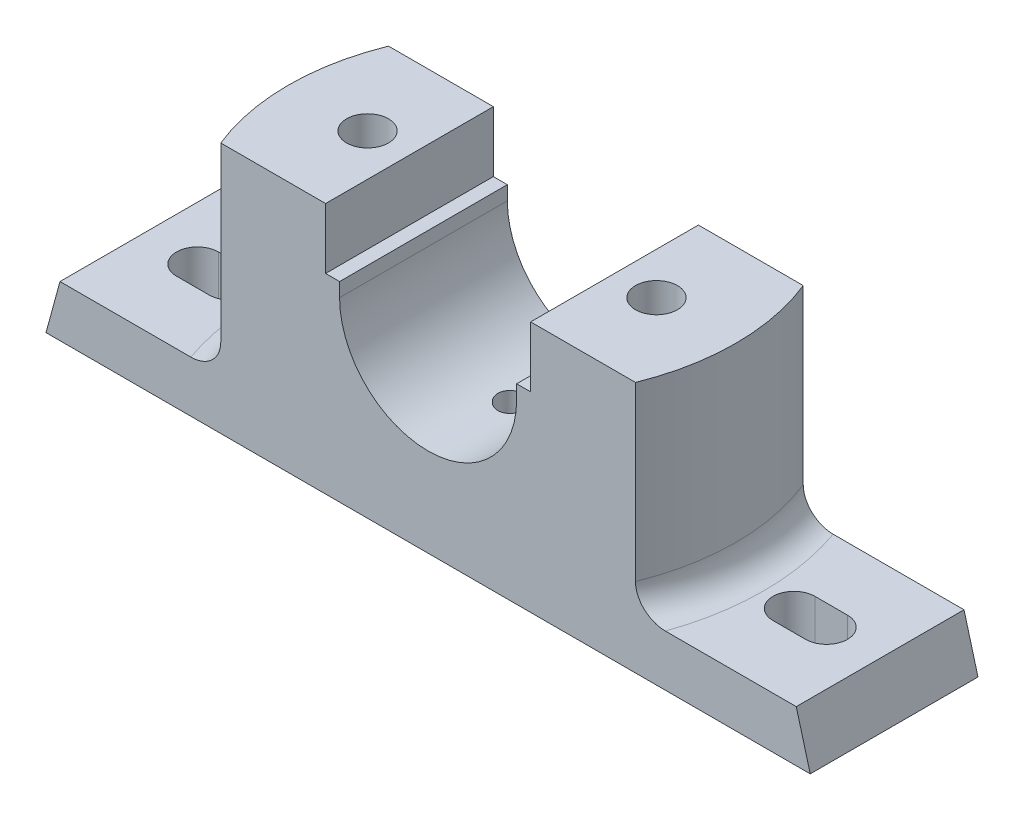
from build123d import *

# Parameters (mm, degrees)
BOSS_EXTRUDE1_DEPTH = 18
CUT_EXTRUDE1_DEPTH  = 43
SKETCH12_W          = 20
SKETCH12_H          = 20
CUT_EXTRUDE2_DEPTH  = 8
SKETCH13_R          = 4.5
CUT_EXTRUDE3_DEPTH  = 55
CUT_EXTRUDE4_DEPTH  = 12
CUT_EXTRUDE8_START  = -6
SKETCH18_R          = 3
CUT_EXTRUDE8_DEPTH  = 6.238337
FILLET1_R           = 6


with BuildPart() as part:
    # Sketch1 → Boss-Extrude1 (new body, symmetric)
    with BuildSketch(Plane.XY):
        with BuildLine():
            Line((82, 0), (-82, 0))
            Line((-82, 0), (-79, 11))
            Line((-79, 11), (-49, 11))
            Line((-49, 11), (-49, 54))
            Line((-49, 54), (-22, 54))
            Line((-22, 54), (-22, 41))
            Line((-22, 41), (-19, 41))
            Line((-19, 41), (-19, 38))
            ThreePointArc((-19, 38), (0, 19), (19, 38))
            Line((19, 38), (19, 41))
            Line((19, 41), (22, 41))
            Line((22, 41), (22, 54))
            Line((22, 54), (49, 54))
            Line((49, 54), (49, 11))
            Line((49, 11), (79, 11))
            Line((79, 11), (82, 0))
        make_face()
    extrude(amount=BOSS_EXTRUDE1_DEPTH, both=True)

    # Sketch3 → Cut-Extrude1 (cut)
    with BuildSketch(Plane(origin=(0, 54, 0), x_dir=(1, 0, 0), z_dir=(0, 1, 0))):
        with BuildLine():
            Line((-44.497190923, 18), (-49, 18))
            Line((-49, 18), (-49, -18))
            Line((-49, -18), (-44.497190923, -18))
            ThreePointArc((-44.497190923, -18), (-48, 0), (-44.497190923, 18))
        make_face()
        with BuildLine():
            Line((49, -18), (49, 18))
            Line((49, 18), (44.497190923, 18))
            ThreePointArc((44.497190923, 18), (48, 0), (44.497190923, -18))
            Line((44.497190923, -18), (49, -18))
        make_face()
    extrude(amount=-CUT_EXTRUDE1_DEPTH, mode=Mode.SUBTRACT)

    # Sketch12 → Cut-Extrude2 (cut)
    with BuildSketch(Plane.XZ):
        with Locations((-31, 0)):
            Rectangle(SKETCH12_W, SKETCH12_H)
        with Locations((31, 0)):
            Rectangle(SKETCH12_W, SKETCH12_H)
    extrude(amount=-CUT_EXTRUDE2_DEPTH, mode=Mode.SUBTRACT)

    # Sketch13 → Cut-Extrude3 (cut, through all)
    with BuildSketch(Plane(origin=(0, 54, 0), x_dir=(1, 0, 0), z_dir=(0, 1, 0))):
        with Locations(Location((-31, 0, 0), (0, 0, 270))):  # turned: the seam where the file's is
            Circle(SKETCH13_R)
        with Locations(Location((31, 0, 0), (0, 0, 270))):  # turned: the seam where the file's is
            Circle(SKETCH13_R)
    extrude(amount=-CUT_EXTRUDE3_DEPTH, mode=Mode.SUBTRACT)

    # Sketch14 → Cut-Extrude4 (cut, through all)
    with BuildSketch(Plane(origin=(0, 11, 0), x_dir=(1, 0, 0), z_dir=(0, 1, 0))):
        with BuildLine():
            Line((-67.5, 4.5), (-60.5, 4.5))
            ThreePointArc((-60.5, 4.5), (-56, 0), (-60.5, -4.5))
            Line((-60.5, -4.5), (-67.5, -4.5))
            ThreePointArc((-67.5, -4.5), (-72, 0), (-67.5, 4.5))
        make_face()
        with BuildLine():
            Line((67.5, 4.5), (60.5, 4.5))
            ThreePointArc((60.5, 4.5), (56, 0), (60.5, -4.5))
            Line((60.5, -4.5), (67.5, -4.5))
            ThreePointArc((67.5, -4.5), (72, 0), (67.5, 4.5))
        make_face()
    extrude(amount=-CUT_EXTRUDE4_DEPTH, mode=Mode.SUBTRACT)

    # Sketch18 → Cut-Extrude8 (cut)
    with BuildSketch(Plane(origin=(0, 19, 0), x_dir=(1, 0, 0), z_dir=(0, 1, 0)).offset(CUT_EXTRUDE8_START)):
        with Locations(Location((0, 0, 0), (0, 0, 270))):  # turned: the seam where the file's is
            Circle(SKETCH18_R)
    extrude(amount=CUT_EXTRUDE8_DEPTH, mode=Mode.SUBTRACT)

    # Fillet1
    fillet1_edges = [part.edges().sort_by_distance(p)[0] for p in [
        (-48, 11, 0),
        (48, 11, 0),
    ]]
    fillet(fillet1_edges, radius=FILLET1_R)


solid = part.part
